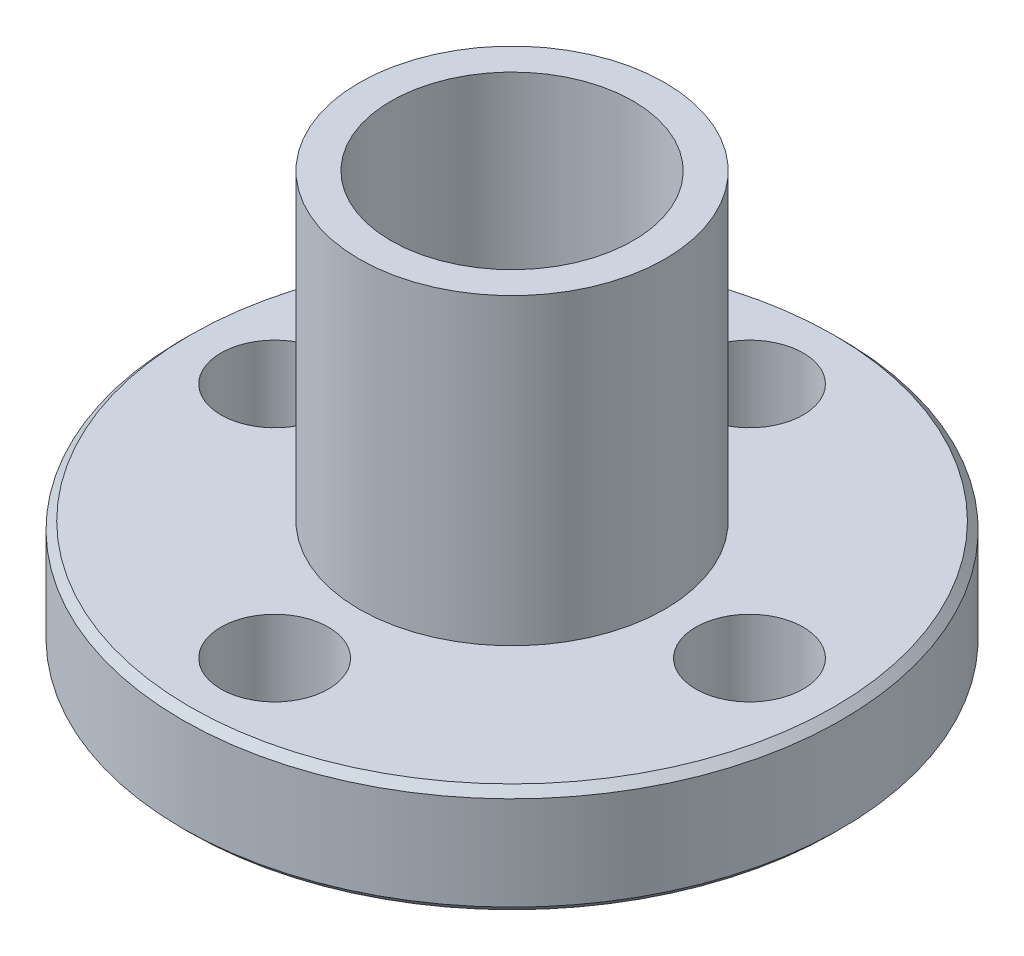
from build123d import *

# Parameters (mm, degrees)
SKETCH1_R                = 10.89025
SKETCH1_R_2              = 1.775
SKETCH1_R_3              = 5.05
BOSS_EXTRUDE1_DEPTH      = 3.6
SKETCH1_3_R              = 5.05
SKETCH1_3_R_2            = 4
BOSS_EXTRUDE2_DEPTH      = 10.02
BOSS_EXTRUDE2_DEPTH_BACK = 5.7927
CHAMFER2_SIZE            = 0.250000008


with BuildPart() as part:
    # Sketch1 → Boss-Extrude1 (new body)
    with BuildSketch(Plane(origin=(0, 0, 0), x_dir=(1, 0, 0), z_dir=(0, 1, 0))):
        Circle(SKETCH1_R)
        with Locations((-7.84525, 0)):
            Circle(SKETCH1_R_2, mode=Mode.SUBTRACT)
        with Locations((0, -7.84525)):
            Circle(SKETCH1_R_2, mode=Mode.SUBTRACT)
        with Locations((7.84525, 0)):
            Circle(SKETCH1_R_2, mode=Mode.SUBTRACT)
        with Locations((0, 7.84525)):
            Circle(SKETCH1_R_2, mode=Mode.SUBTRACT)
        Circle(SKETCH1_R_3, mode=Mode.SUBTRACT)
    extrude(amount=-BOSS_EXTRUDE1_DEPTH)

    # Chamfer2
    chamfer2_edges = [part.edges().sort_by_distance(p)[0] for p in [
        (-10.89025, -3.6, 0),
        (-10.89025, 0, 0),
    ]]
    chamfer(chamfer2_edges, length=CHAMFER2_SIZE)


with BuildPart() as body_2:
    # Sketch1_3 → Boss-Extrude2 (new body, two sides)
    with BuildSketch(Plane(origin=(0, 0, 0), x_dir=(1, 0, 0), z_dir=(0, 1, 0))) as boss_extrude2_sk:
        Circle(SKETCH1_3_R)
        Circle(SKETCH1_3_R_2, mode=Mode.SUBTRACT)
    extrude(amount=BOSS_EXTRUDE2_DEPTH)
    extrude(boss_extrude2_sk.sketch, amount=-BOSS_EXTRUDE2_DEPTH_BACK)


solid = Compound([part.part, body_2.part])
